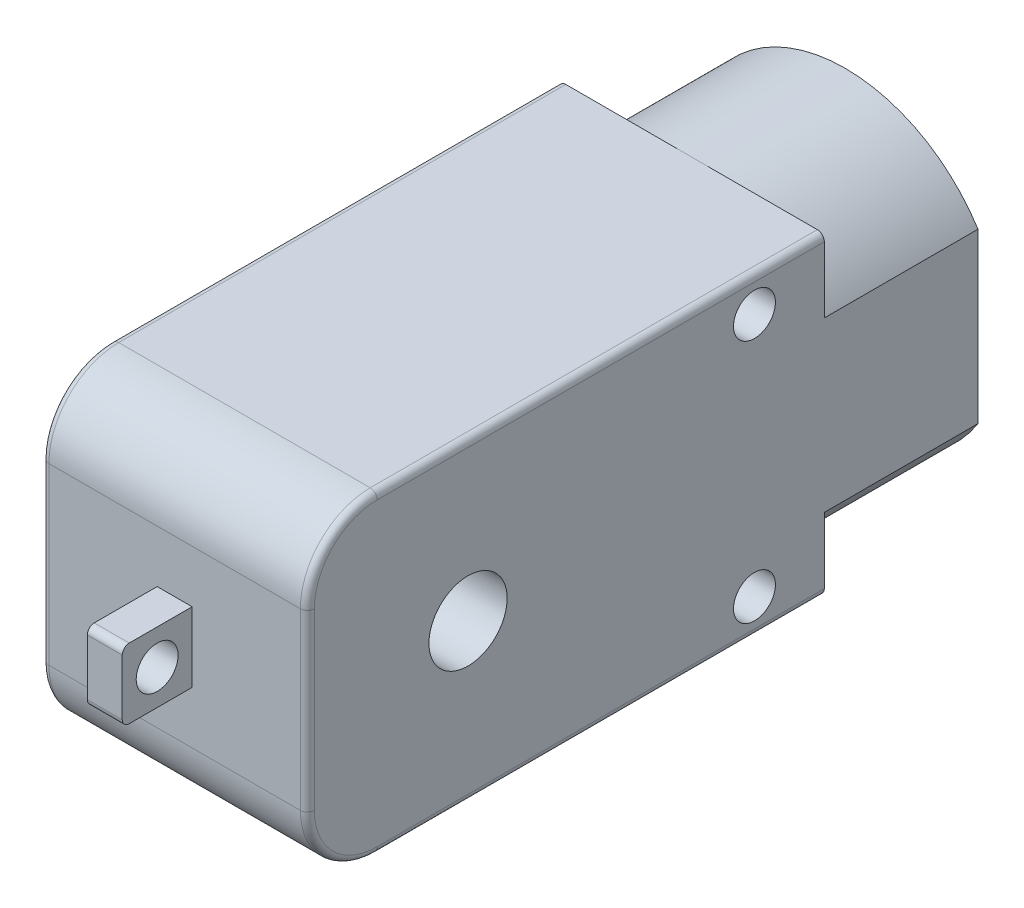
from build123d import *

# Parameters (mm, degrees)
SKETCH1_W           = 19
SKETCH1_H           = 22.5
BOSS_EXTRUDE1_DEPTH = 37
BOSS_EXTRUDE2_DEPTH = 11
FILLET1_R           = 5
SKETCH3_R           = 1.5
CUT_EXTRUDE1_DEPTH  = 20
SKETCH4_W           = 2.5
SKETCH4_H           = 5
BOSS_EXTRUDE3_DEPTH = 5
FILLET2_R           = 0.5
SKETCH5_R           = 1.5
CUT_EXTRUDE2_DEPTH  = 5
SKETCH6_R           = 2.8
CUT_EXTRUDE3_DEPTH  = 20
CUT_EXTRUDE4_DEPTH  = 11
SKETCH8_R           = 3
CUT_EXTRUDE5_DEPTH  = 2


with BuildPart() as part:
    # Sketch1 → Boss-Extrude1 (new body)
    with BuildSketch(Plane.XY):
        Rectangle(SKETCH1_W, SKETCH1_H)
    extrude(amount=BOSS_EXTRUDE1_DEPTH)

    # Sketch2 → Boss-Extrude2 (add)
    with BuildSketch(Plane(origin=(0, 0, 0), x_dir=(-1, 0, 0), z_dir=(0, 0, -1))):
        with BuildLine():
            Line((9.5, 6.025985397), (9.5, -6.025985397))
            ThreePointArc((9.5, -6.025985397), (0, -11.25), (-9.5, -6.025985397))
            Line((-9.5, -6.025985397), (-9.5, 6.025985397))
            ThreePointArc((-9.5, 6.025985397), (0, 11.25), (9.5, 6.025985397))
        make_face()
    extrude(amount=BOSS_EXTRUDE2_DEPTH)

    # Fillet1
    fillet1_edges = [part.edges().sort_by_distance(p)[0] for p in [
        (0, 11.25, 37),
        (0, -11.25, 37),
    ]]
    fillet(fillet1_edges, radius=FILLET1_R)

    # Sketch3 → Cut-Extrude1 (cut, through all)
    with BuildSketch(Plane(origin=(9.5, 0, 0), x_dir=(0, 0, -1), z_dir=(1, 0, 0))):
        with Locations((-5, 8.75)):
            Circle(SKETCH3_R)
        with Locations((-5, -8.75)):
            Circle(SKETCH3_R)
    extrude(amount=-CUT_EXTRUDE1_DEPTH, mode=Mode.SUBTRACT)

    # Sketch4 → Boss-Extrude3 (add)
    with BuildSketch(Plane.XY.offset(37)):
        Rectangle(SKETCH4_W, SKETCH4_H)
    extrude(amount=BOSS_EXTRUDE3_DEPTH)

    # Fillet2
    fillet2_edges = [part.edges().sort_by_distance(p)[0] for p in [
        (-9.5, 0, 37),
        (9.5, 0, 37),
        (9.5, 11.25, 16),
        (9.5, -11.25, 16),
        (9.5, 9.785533906, 35.535533906),
        (9.5, -9.785533906, 35.535533906),
        (-9.5, -11.25, 16),
        (-9.5, 11.25, 16),
        (-9.5, 9.785533906, 35.535533906),
        (-9.5, -9.785533906, 35.535533906),
        (0, -2.5, 42),
        (0, 2.5, 42),
    ]]
    fillet(fillet2_edges, radius=FILLET2_R)

    # Sketch5 → Cut-Extrude2 (cut)
    with BuildSketch(Plane(origin=(1.25, 0, 0), x_dir=(0, 0, -1), z_dir=(1, 0, 0))):
        with Locations((-39.5, 0)):
            Circle(SKETCH5_R)
    extrude(amount=-CUT_EXTRUDE2_DEPTH, mode=Mode.SUBTRACT)

    # Sketch6 → Cut-Extrude3 (cut, through all)
    with BuildSketch(Plane(origin=(9.5, 0, 0), x_dir=(0, 0, -1), z_dir=(1, 0, 0))):
        with Locations((-25.5, 0)):
            Circle(SKETCH6_R)
    extrude(amount=-CUT_EXTRUDE3_DEPTH, mode=Mode.SUBTRACT)

    # Sketch7 → Cut-Extrude4 (cut)
    with BuildSketch(Plane(origin=(0, 0, -11), x_dir=(-1, 0, 0), z_dir=(0, 0, -1))):
        with BuildLine():
            Line((-8.3, 5.666789214), (-8.3, -5.666789214))
            ThreePointArc((-8.3, -5.666789214), (0, -10.05), (8.3, -5.666789214))
            Line((8.3, -5.666789214), (8.3, 5.666789214))
            ThreePointArc((8.3, 5.666789214), (0, 10.05), (-8.3, 5.666789214))
        make_face()
    extrude(amount=-CUT_EXTRUDE4_DEPTH, mode=Mode.SUBTRACT)

    # Sketch8 → Cut-Extrude5 (cut)
    with BuildSketch(Plane(origin=(0, 0, 0), x_dir=(-1, 0, 0), z_dir=(0, 0, -1))):
        Circle(SKETCH8_R)
    extrude(amount=-CUT_EXTRUDE5_DEPTH, mode=Mode.SUBTRACT)


solid = part.part
